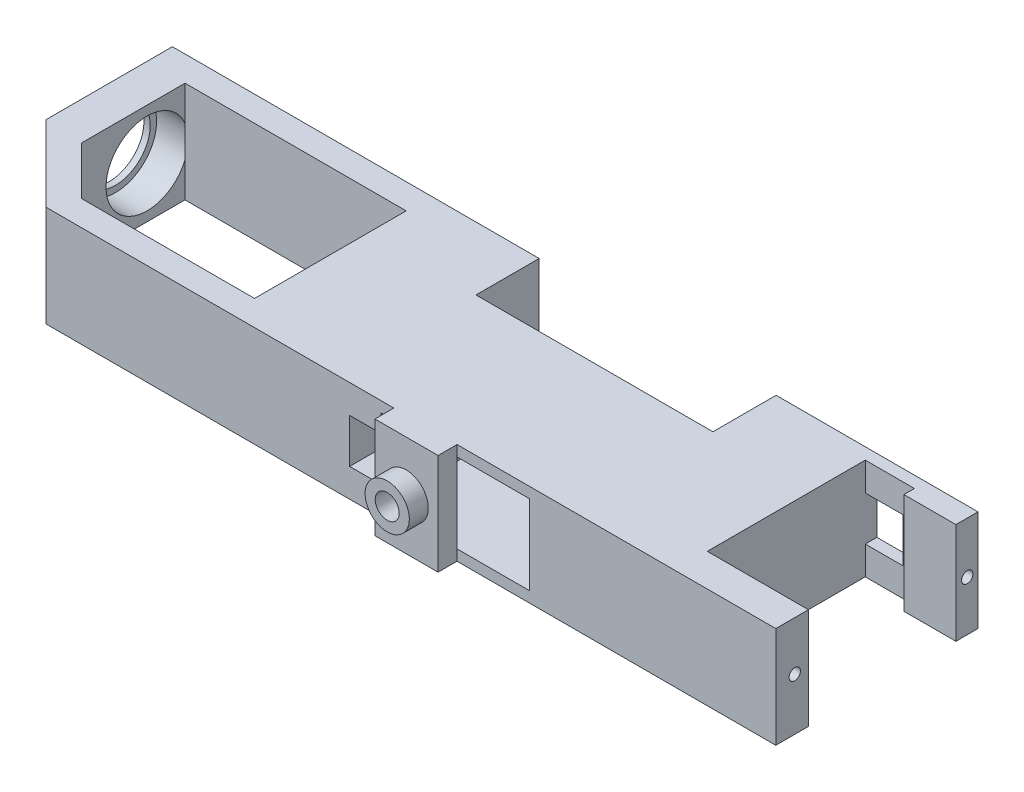
from build123d import *

# Parameters (mm, degrees)
BOSS_EXTRUDE1_DEPTH      = 8
BOSS_EXTRUDE1_DEPTH_BACK = 8
SKETCH2_R                = 5.5
CUT_EXTRUDE1_DEPTH       = 8
CUT_EXTRUDE2_DEPTH       = 16
SKETCH4_R                = 6.5
CUT_EXTRUDE3_DEPTH       = 5
SKETCH5_W                = 23.5
SKETCH5_H                = 12.6
CUT_EXTRUDE4_DEPTH       = 33
SKETCH6_R                = 0.9
CUT_EXTRUDE5_DEPTH       = 17
SKETCH7_W                = 6
SKETCH7_H                = 7
CUT_EXTRUDE6_DEPTH       = 7
SKETCH8_W                = 5
SKETCH8_H                = 7
CUT_EXTRUDE7_DEPTH       = 10
SKETCH9_R                = 0.899999999
CUT_EXTRUDE8_DEPTH       = 7
SKETCH10_W               = 37.5
SKETCH10_H               = 16
CUT_EXTRUDE9_DEPTH       = 10
SKETCH11_W               = 10
SKETCH11_H               = 16
BOSS_EXTRUDE2_DEPTH      = 3
SKETCH12_R               = 3.5
SKETCH12_R_2             = 1.9
BOSS_EXTRUDE3_DEPTH      = 3
SKETCH13_R               = 1.9
CUT_EXTRUDE10_DEPTH      = 3


with BuildPart() as part:
    # Sketch1 → Boss-Extrude1 (new body, two sides)
    with BuildSketch(Plane(origin=(0, 0, 0), x_dir=(1, 0, 0), z_dir=(0, 1, 0))) as boss_extrude1_sk:
        Polygon((64, -16.835969506), (47.993540801, -16.835969506), (47.993540801, 8.164030494), (55.763890835, 8.164030494), (55.763890835, 6.5), (64, 6.5), (64, 10), (-63.5, 10), (-63.5, -10), (-51.5, -22), (64, -22), align=None)
    extrude(amount=BOSS_EXTRUDE1_DEPTH)
    extrude(boss_extrude1_sk.sketch, amount=-BOSS_EXTRUDE1_DEPTH_BACK)

    # Sketch2 → Cut-Extrude1 (cut)
    with BuildSketch(Plane.ZY.offset(63.5)):
        Circle(SKETCH2_R)
    extrude(amount=-CUT_EXTRUDE1_DEPTH, mode=Mode.SUBTRACT)

    # Sketch3 → Cut-Extrude2 (cut)
    with BuildSketch(Plane(origin=(0, 8, 0), x_dir=(1, 0, 0), z_dir=(0, 1, 0))):
        Polygon((-57.5, 6), (-22.5, 6), (-22.5, -18), (-49.843145751, -18), (-57.5, -10.343145751), align=None)
    extrude(amount=-CUT_EXTRUDE2_DEPTH, mode=Mode.SUBTRACT)

    # Sketch4 → Cut-Extrude3 (cut)
    with BuildSketch(Plane(origin=(-57.5, 0, 0), x_dir=(0, 0, -1), z_dir=(1, 0, 0))):
        Circle(SKETCH4_R)
    extrude(amount=-CUT_EXTRUDE3_DEPTH, mode=Mode.SUBTRACT)

    # Sketch5 → Cut-Extrude4 (cut, through all)
    with BuildSketch(Plane(origin=(0, 0, -10), x_dir=(-1, 0, 0), z_dir=(0, 0, -1))):
        with Locations((-13.3, 0)):
            Rectangle(SKETCH5_W, SKETCH5_H)
    extrude(amount=-CUT_EXTRUDE4_DEPTH, mode=Mode.SUBTRACT)

    # Sketch6 → Cut-Extrude5 (cut)
    with BuildSketch(Plane(origin=(0, 0, -10), x_dir=(-1, 0, 0), z_dir=(0, 0, -1))):
        with Locations((-0.2, 0)):
            Circle(SKETCH6_R)
        with Locations((-27.5, 0)):
            Circle(SKETCH6_R)
    extrude(amount=-CUT_EXTRUDE5_DEPTH, mode=Mode.SUBTRACT)

    # Sketch7 → Cut-Extrude6 (cut)
    with BuildSketch(Plane(origin=(0, 0, -10), x_dir=(-1, 0, 0), z_dir=(0, 0, -1))):
        with Locations((-50.993540801, 0)):
            Rectangle(SKETCH7_W, SKETCH7_H)
    extrude(amount=-CUT_EXTRUDE6_DEPTH, mode=Mode.SUBTRACT)

    # Sketch8 → Cut-Extrude7 (cut)
    with BuildSketch(Plane.XY.offset(22)):
        with Locations((-0.95, 0)):
            Rectangle(SKETCH8_W, SKETCH8_H)
    extrude(amount=-CUT_EXTRUDE7_DEPTH, mode=Mode.SUBTRACT)

    # Sketch9 → Cut-Extrude8 (cut)
    with BuildSketch(Plane(origin=(64, 0, 0), x_dir=(0, 0, -1), z_dir=(1, 0, 0))):
        with Locations((-18.998394534, 0.246992199)):
            Circle(SKETCH9_R)
        with Locations((8.299298665, -0.107896588)):
            Circle(SKETCH9_R)
    extrude(amount=-CUT_EXTRUDE8_DEPTH, mode=Mode.SUBTRACT)

    # Sketch10 → Cut-Extrude9 (cut)
    with BuildSketch(Plane(origin=(0, 0, -10), x_dir=(-1, 0, 0), z_dir=(0, 0, -1))):
        with Locations((-13.3, 0)):
            Rectangle(SKETCH10_W, SKETCH10_H)
    extrude(amount=-CUT_EXTRUDE9_DEPTH, mode=Mode.SUBTRACT)

    # Sketch11 → Boss-Extrude2 (add)
    with BuildSketch(Plane.XY.offset(22)):
        with Locations((8.55, 0)):
            Rectangle(SKETCH11_W, SKETCH11_H)
    extrude(amount=BOSS_EXTRUDE2_DEPTH)

    # Sketch12 → Boss-Extrude3 (add)
    with BuildSketch(Plane.XY.offset(25)):
        with Locations((8.499999912, 0)):
            Circle(SKETCH12_R)
        with Locations((8.499999912, 0)):
            Circle(SKETCH12_R_2, mode=Mode.SUBTRACT)
    extrude(amount=BOSS_EXTRUDE3_DEPTH)

    # Sketch13 → Cut-Extrude10 (cut)
    with BuildSketch(Plane.XY.offset(25)):
        with Locations((8.499999912, 0)):
            Circle(SKETCH13_R)
    extrude(amount=-CUT_EXTRUDE10_DEPTH, mode=Mode.SUBTRACT)


solid = part.part
